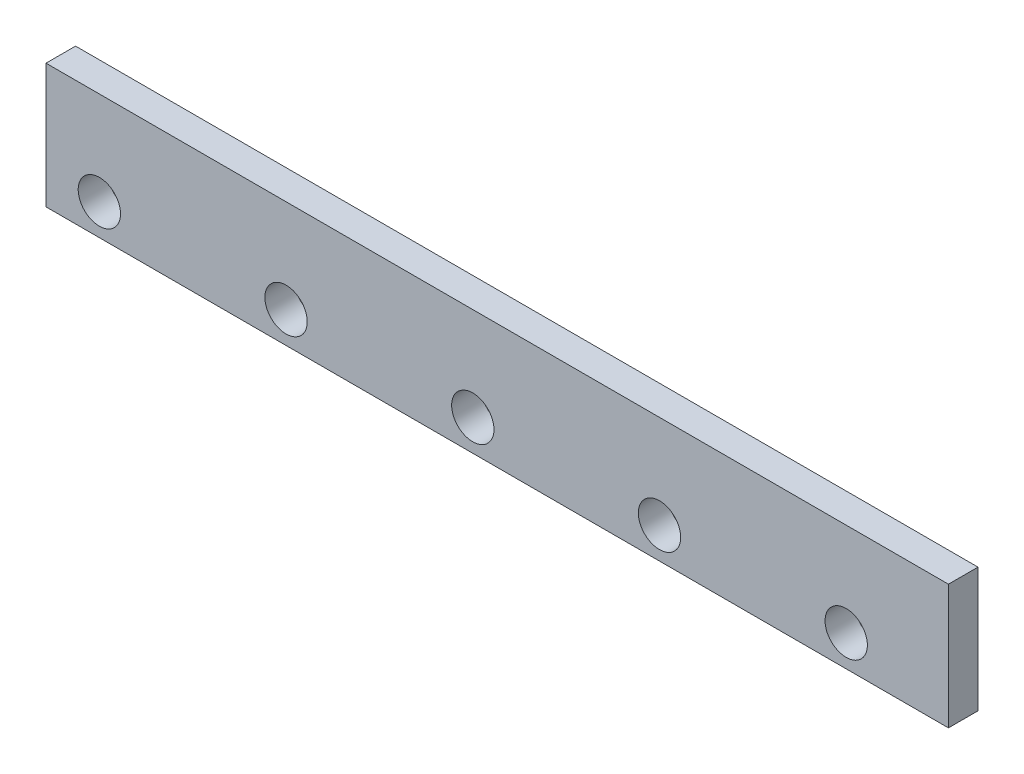
from build123d import *

# Parameters (mm, degrees)
SKETCH2_W           = 580
SKETCH2_H           = 80
SKETCH2_R           = 13.606862629
BOSS_EXTRUDE1_DEPTH = 19


with BuildPart() as part:
    # Sketch2 → Boss-Extrude1 (new body)
    with BuildSketch(Plane.XY):
        with Locations((290, 40)):
            Rectangle(SKETCH2_W, SKETCH2_H)
        with Locations((34.29916653, 20.001482831)):
            Circle(SKETCH2_R, mode=Mode.SUBTRACT)
        with Locations((154.29916653, 20.001482831)):
            Circle(SKETCH2_R, mode=Mode.SUBTRACT)
        with Locations((274.29916653, 20.001482831)):
            Circle(SKETCH2_R, mode=Mode.SUBTRACT)
        with Locations((394.29916653, 20.001482831)):
            Circle(SKETCH2_R, mode=Mode.SUBTRACT)
        with Locations((514.29916653, 20.001482831)):
            Circle(SKETCH2_R, mode=Mode.SUBTRACT)
    extrude(amount=BOSS_EXTRUDE1_DEPTH)


solid = part.part
